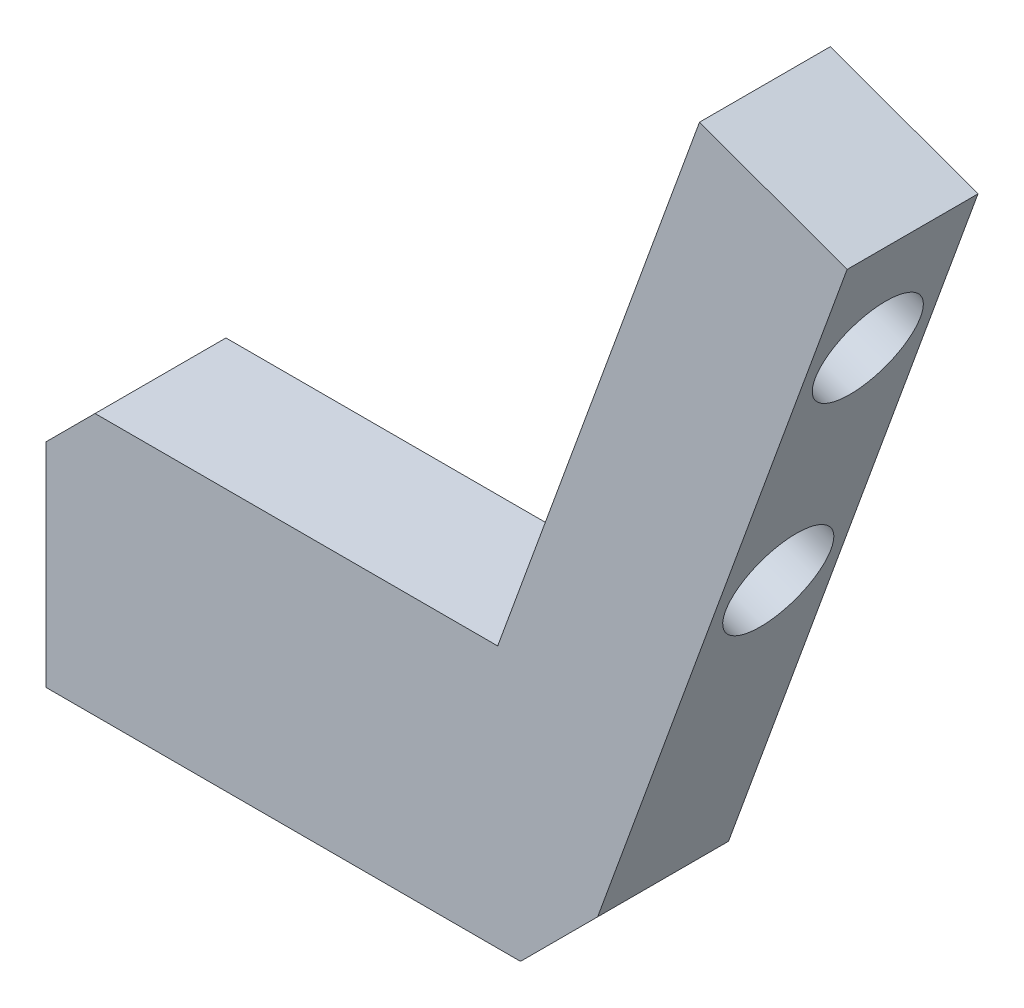
from build123d import *

# Parameters (mm, degrees)
BOSS_EXTRUDE1_DEPTH            = 3.175
TAP_DRILL_FOR_10_24_TAP1_D     = 3.7973
TAP_DRILL_FOR_10_24_TAP1_DEPTH = 10.16
TAP_DRILL_FOR_10_24_TAP1_TIP   = 1.140824014
CHAMFER1_SIZE                  = 2.38
CHAMFER1_EDGE_2_SIZE2          = 3.982114101
CHAMFER1_EDGE_2_SIZE           = 2.38
F_10_CLEARANCE_HOLE1_D         = 5.1054
F_10_CLEARANCE_HOLE1_DEPTH     = 12.7
F_10_CLEARANCE_HOLE1_TIP       = 1.533816902


with BuildPart() as part:
    # Sketch1 → Boss-Extrude1 (new body, symmetric)
    with BuildSketch(Plane.XY):
        Polygon((-25.4, 0), (0, 0), (13.465333043, 36.99569848), (6.304875272, 39.601891972), (-3.486612651, 12.7), (-25.4, 12.7), align=None)
    extrude(amount=BOSS_EXTRUDE1_DEPTH, both=True)

    # Tap Drill for #10-24 Tap1
    with Locations(Plane(origin=(0, 0, 0), x_dir=(-1, 0, 0), z_dir=(0, -1, 0))):
        with Locations((22.225, 0), (9.525, 0)):
            Hole(TAP_DRILL_FOR_10_24_TAP1_D / 2, depth=TAP_DRILL_FOR_10_24_TAP1_DEPTH)
            with Locations((0, 0, -(TAP_DRILL_FOR_10_24_TAP1_DEPTH + TAP_DRILL_FOR_10_24_TAP1_TIP / 2))):  # 118° drill point
                Cone(0, TAP_DRILL_FOR_10_24_TAP1_D / 2, TAP_DRILL_FOR_10_24_TAP1_TIP, mode=Mode.SUBTRACT)

    # Chamfer1
    chamfer1_edges = [part.edges().sort_by_distance(p)[0] for p in [
        (-25.4, 12.7, 0),
    ]]
    chamfer(chamfer1_edges, length=CHAMFER1_SIZE)

    # Chamfer1 edge 2
    chamfer1_edge_2_edges = [part.edges().sort_by_distance(p)[0] for p in [
        (0, 0, 0),
    ]]
    chamfer(chamfer1_edge_2_edges, length=CHAMFER1_EDGE_2_SIZE, length2=CHAMFER1_EDGE_2_SIZE2)

    # #10 Clearance Hole1
    with Locations(Plane(origin=(0, 0, 0), x_dir=(0, 0, -1), z_dir=(0.939692621, -0.342020143, 0))):
        with Locations((0, 33.02), (0, 20.32)):
            Hole(F_10_CLEARANCE_HOLE1_D / 2, depth=F_10_CLEARANCE_HOLE1_DEPTH)
            with Locations((0, 0, -(F_10_CLEARANCE_HOLE1_DEPTH + F_10_CLEARANCE_HOLE1_TIP / 2))):  # 118° drill point
                Cone(0, F_10_CLEARANCE_HOLE1_D / 2, F_10_CLEARANCE_HOLE1_TIP, mode=Mode.SUBTRACT)


solid = part.part
